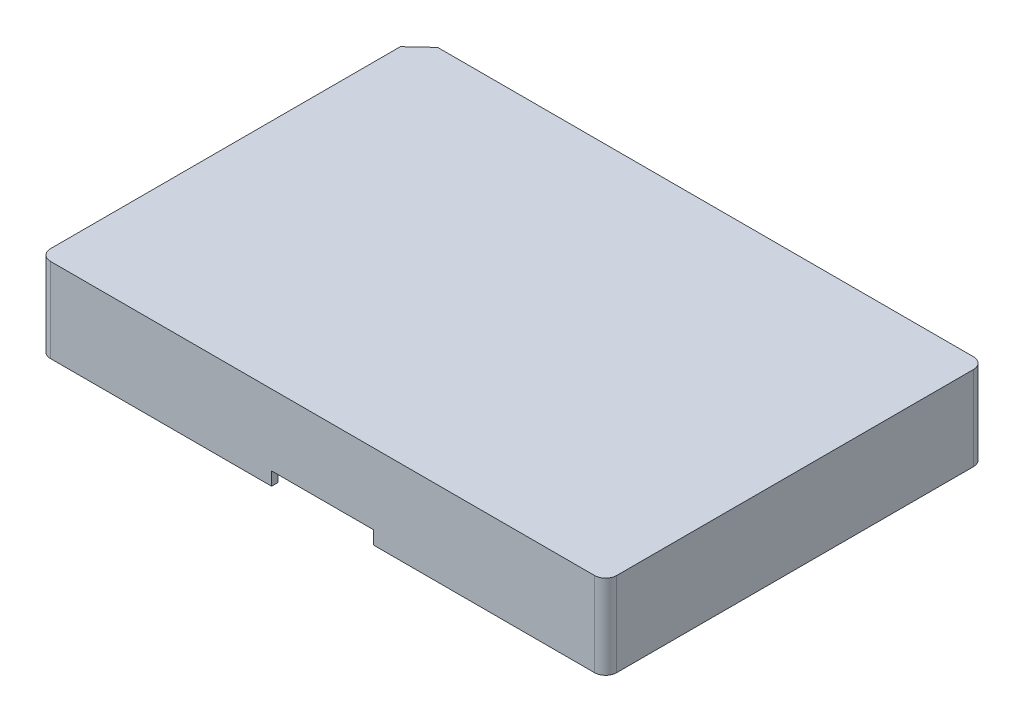
from build123d import *

# Parameters (mm, degrees)
BOSS_EXTRUDE1_DEPTH     = 19
FILLET1_R               = 2.5
SHELL1_T                = -1.5
SKETCH4_W               = 23
SKETCH4_H               = 3
CUT_EXTRUDE1_DEPTH      = 119.285320442
CUT_EXTRUDE1_DEPTH_BACK = 1


with BuildPart() as part:
    # Sketch3 → Boss-Extrude1 (new body)
    with BuildSketch(Plane(origin=(0, 0, 0), x_dir=(1, 0, 0), z_dir=(0, 1, 0))):
        Polygon((68.461632103, -32.785320442), (-54.932531078, -32.785320442), (-59.288367897, -36.85076814), (-59.288367897, -118.285320442), (68.461632103, -118.285320442), align=None)
    extrude(amount=BOSS_EXTRUDE1_DEPTH)

    # Fillet1
    fillet1_edges = [part.edges().sort_by_distance(p)[0] for p in [
        (68.461632103, 9.5, 32.785320442),
        (68.461632103, 9.5, 118.285320442),
        (-59.288367897, 9.5, 118.285320442),
    ]]
    fillet(fillet1_edges, radius=FILLET1_R)

    # Shell1
    shell1_openings = [part.faces().sort_by_distance(p)[0] for p in [
        (4.883332574, 0, 75.795722274),
    ]]
    offset(amount=SHELL1_T, openings=shell1_openings, kind=Kind.INTERSECTION)

    # Sketch4 → Cut-Extrude1 (cut, two sides)
    with BuildSketch(Plane.XY) as cut_extrude1_sk:
        with Locations((4.586632103, 1.5)):
            Rectangle(SKETCH4_W, SKETCH4_H)
    extrude(amount=CUT_EXTRUDE1_DEPTH, mode=Mode.SUBTRACT)
    extrude(cut_extrude1_sk.sketch, amount=-CUT_EXTRUDE1_DEPTH_BACK, mode=Mode.SUBTRACT)


solid = part.part
